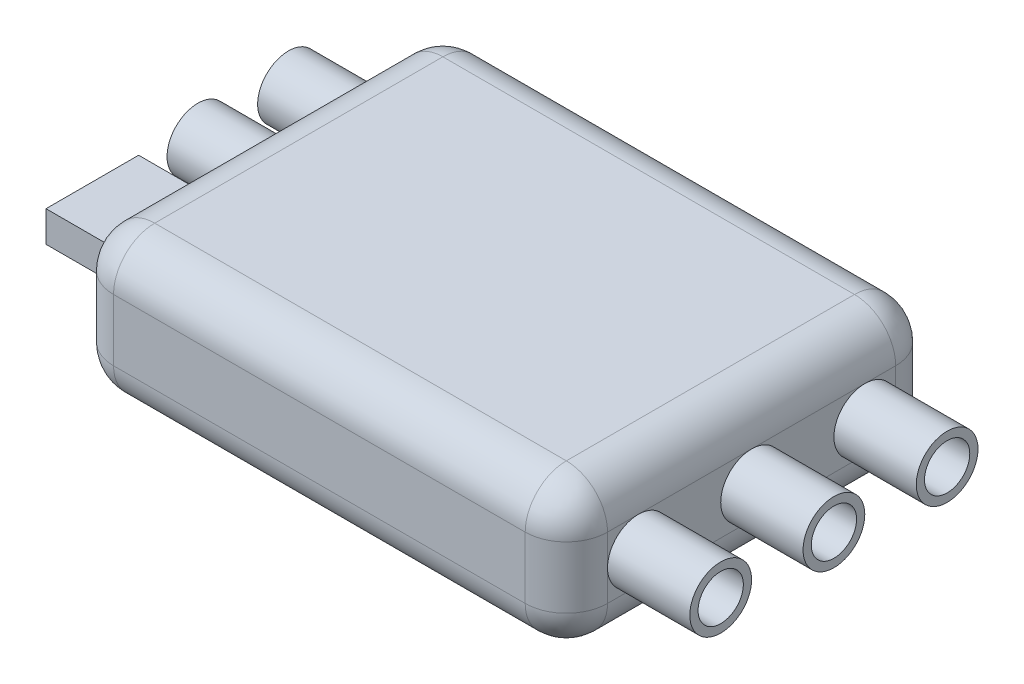
from build123d import *

# Parameters (mm, degrees)
BOSS_EXTRUDE1_DEPTH = 7
FILLET1_R           = 2
SKETCH2_R           = 1.5
SKETCH2_R_2         = 1.1
BOSS_EXTRUDE2_DEPTH = 4
SKETCH3_R           = 1.5
SKETCH3_R_2         = 1.1
SKETCH3_W           = 4.5
SKETCH3_H           = 1.5
BOSS_EXTRUDE3_DEPTH = 4


with BuildPart() as part:
    # Sketch1 → Boss-Extrude1 (new body)
    with BuildSketch(Plane(origin=(0, 0, 0), x_dir=(1, 0, 0), z_dir=(0, 1, 0))):
        with BuildLine():
            Line((10, -9), (-10, -9))
            ThreePointArc((-10, -9), (-11.414213562, -8.414213562), (-12, -7))
            Line((-12, -7), (-12, 7))
            ThreePointArc((-12, 7), (-11.414213562, 8.414213562), (-10, 9))
            Line((-10, 9), (10, 9))
            ThreePointArc((10, 9), (11.414213562, 8.414213562), (12, 7))
            Line((12, 7), (12, -7))
            ThreePointArc((12, -7), (11.414213562, -8.414213562), (10, -9))
        make_face()
    extrude(amount=BOSS_EXTRUDE1_DEPTH)

    # Fillet1
    fillet1_edges = [part.edges().sort_by_distance(p)[0] for p in [
        (11.414213562, 7, 8.414213562),
        (0, 0, 9),
        (-11.414213562, 0, 8.414213562),
        (12, 7, 0),
        (11.414213562, 7, -8.414213562),
        (0, 7, -9),
        (-11.414213562, 7, -8.414213562),
        (-12, 7, 0),
        (-11.414213562, 7, 8.414213562),
        (0, 7, 9),
        (-12, 0, 0),
        (-11.414213562, 0, -8.414213562),
        (0, 0, -9),
        (11.414213562, 0, -8.414213562),
        (12, 0, 0),
        (11.414213562, 0, 8.414213562),
    ]]
    fillet(fillet1_edges, radius=FILLET1_R)

    # Sketch2 → Boss-Extrude2 (add)
    with BuildSketch(Plane(origin=(12, 0, 0), x_dir=(0, 0, -1), z_dir=(1, 0, 0))):
        with Locations((0, 3.5)):
            Circle(SKETCH2_R)
        with Locations((0, 3.5)):
            Circle(SKETCH2_R_2, mode=Mode.SUBTRACT)
        with Locations((-5.5, 3.5)):
            Circle(SKETCH2_R)
        with Locations((-5.5, 3.5)):
            Circle(SKETCH2_R_2, mode=Mode.SUBTRACT)
        with Locations((5.5, 3.5)):
            Circle(SKETCH2_R)
        with Locations((5.5, 3.5)):
            Circle(SKETCH2_R_2, mode=Mode.SUBTRACT)
    extrude(amount=BOSS_EXTRUDE2_DEPTH)

    # Sketch3 → Boss-Extrude3 (add)
    with BuildSketch(Plane.ZY.offset(12)):
        with Locations((-5.5, 3.5)):
            Circle(SKETCH3_R)
        with Locations((-5.5, 3.5)):
            Circle(SKETCH3_R_2, mode=Mode.SUBTRACT)
        with Locations((-1.1, 3.5)):
            Circle(SKETCH3_R)
        with Locations((-1.1, 3.5)):
            Circle(SKETCH3_R_2, mode=Mode.SUBTRACT)
        with Locations((4.031327063, 3.5)):
            Rectangle(SKETCH3_W, SKETCH3_H)
    extrude(amount=BOSS_EXTRUDE3_DEPTH)


solid = part.part
